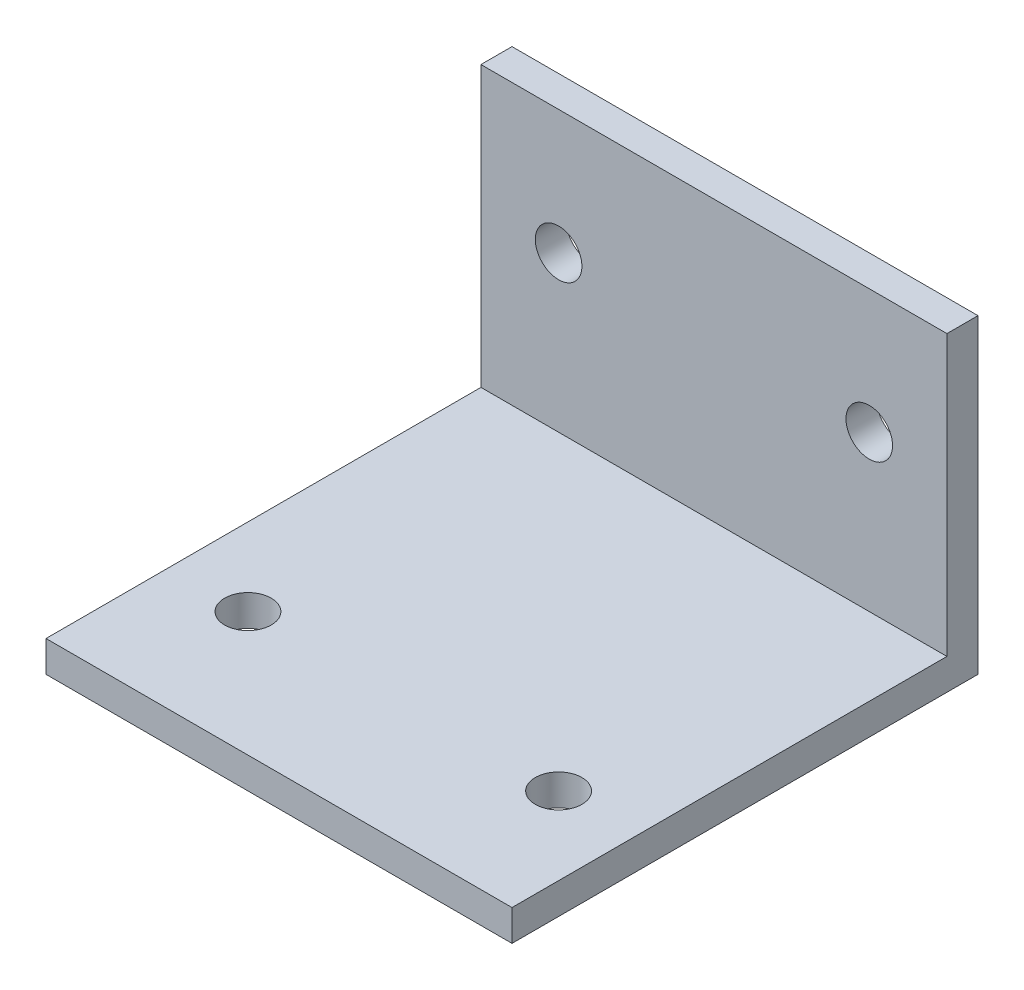
from build123d import *

# Parameters (mm, degrees)
SKETCH_1_W          = 30
SKETCH_1_H          = 38
EXTRUDE_1_DEPTH     = 3
SKETCH_2_W          = 30
SKETCH_2_H          = 3
EXTRUDE_2_DEPTH     = 35
SKETCH_3_R          = 1.5
CUT_EXTRUDE_1_DEPTH = 35
SKETCH_4_R          = 1.5
CUT_EXTRUDE_2_DEPTH = 35
SKETCH_5_W          = 88.636762999
SKETCH_5_H          = 63.593874591
CUT_EXTRUDE_3_DEPTH = 1
SKETCH_6_W          = 48.892654417
SKETCH_6_H          = 42.932057718
CUT_EXTRUDE_4_DEPTH = 1
SKETCH_7_W          = 36.310850366
SKETCH_7_H          = 6.739338697
CUT_EXTRUDE_5_DEPTH = 7
SKETCH_8_W          = 38.639290764
SKETCH_8_H          = 12.957782525
CUT_EXTRUDE_6_DEPTH = 17


with BuildPart() as part:
    # 草图1 → 凸台-拉伸1 (new body)
    with BuildSketch(Plane.XY):
        Rectangle(SKETCH_1_W, SKETCH_1_H)
    extrude(amount=EXTRUDE_1_DEPTH)

    # 草图2 → 凸台-拉伸2 (add)
    with BuildSketch(Plane.XY.offset(3)):
        with Locations((0, -17.5)):
            Rectangle(SKETCH_2_W, SKETCH_2_H)
    extrude(amount=EXTRUDE_2_DEPTH)

    # 草图3 → 切除-拉伸1 (cut)
    with BuildSketch(Plane.XY.offset(3)):
        with Locations((-10, -6)):
            Circle(SKETCH_3_R)
        with Locations((10, -6)):
            Circle(SKETCH_3_R)
    extrude(amount=-CUT_EXTRUDE_1_DEPTH, mode=Mode.SUBTRACT)

    # 草图4 → 切除-拉伸2 (cut)
    with BuildSketch(Plane(origin=(0, -16, 0), x_dir=(1, 0, 0), z_dir=(0, 1, 0))):
        with Locations((-10, -23)):
            Circle(SKETCH_4_R)
        with Locations((10, -23)):
            Circle(SKETCH_4_R)
    extrude(amount=-CUT_EXTRUDE_2_DEPTH, mode=Mode.SUBTRACT)

    # 草图5 → 切除-拉伸3 (cut)
    with BuildSketch(Plane.XZ.offset(19)):
        with Locations((3.130084419, 17.677441591)):
            Rectangle(SKETCH_5_W, SKETCH_5_H)
    extrude(amount=-CUT_EXTRUDE_3_DEPTH, mode=Mode.SUBTRACT)

    # 草图6 → 切除-拉伸4 (cut)
    with BuildSketch(Plane(origin=(0, 0, 0), x_dir=(-1, 0, 0), z_dir=(0, 0, -1))):
        with Locations((1.260467489, 1.250792639)):
            Rectangle(SKETCH_6_W, SKETCH_6_H)
    extrude(amount=-CUT_EXTRUDE_4_DEPTH, mode=Mode.SUBTRACT)

    # 草图7 → 切除-拉伸5 (cut)
    with BuildSketch(Plane.XY.offset(38)):
        with Locations((-0.942459464, -16.150780979)):
            Rectangle(SKETCH_7_W, SKETCH_7_H)
    extrude(amount=-CUT_EXTRUDE_5_DEPTH, mode=Mode.SUBTRACT)

    # 草图8 → 切除-拉伸6 (cut)
    with BuildSketch(Plane(origin=(0, 19, 0), x_dir=(1, 0, 0), z_dir=(0, 1, 0))):
        with Locations((-0.082193205, -0.869277183)):
            Rectangle(SKETCH_8_W, SKETCH_8_H)
    extrude(amount=-CUT_EXTRUDE_6_DEPTH, mode=Mode.SUBTRACT)


solid = part.part
